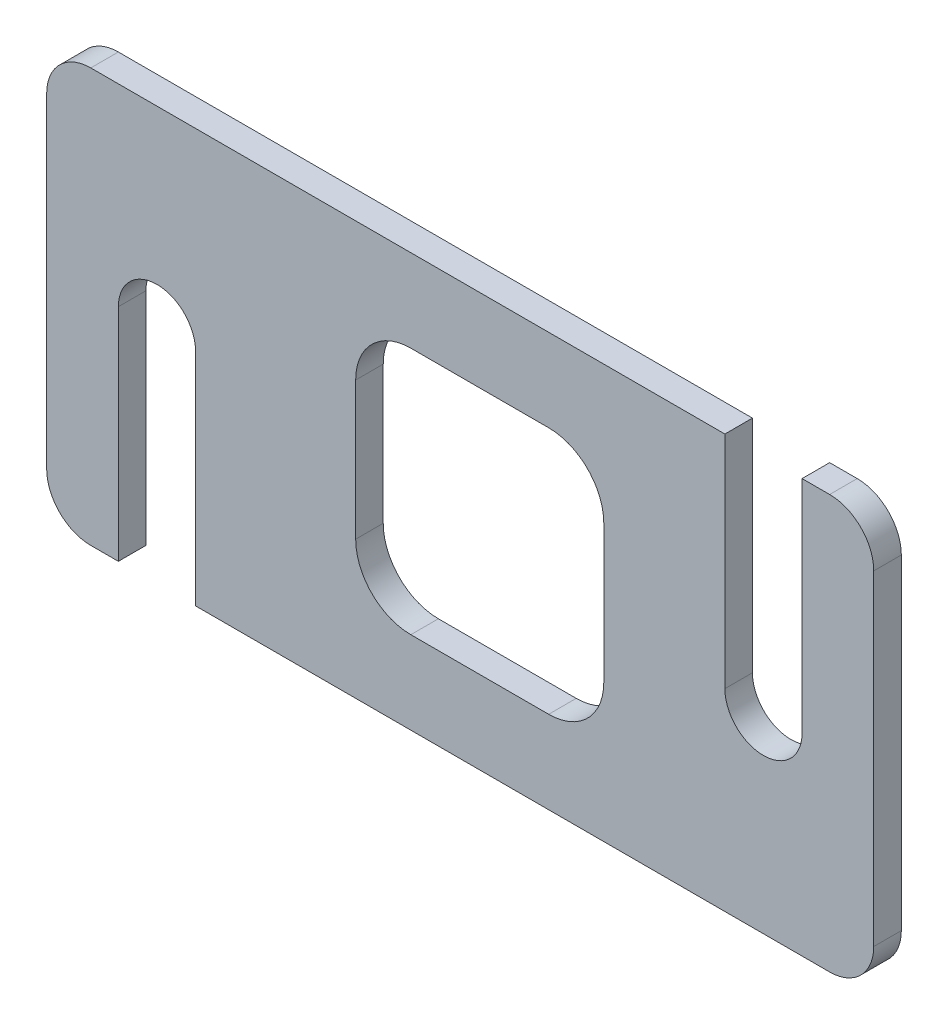
from build123d import *

# Parameters (mm, degrees)
SKETCH1_W                = 150
SKETCH1_H                = 75
BOSS_EXTRUDE2_DEPTH      = 5
CUT_EXTRUDE9_DEPTH       = 6
CUT_EXTRUDE9_DEPTH_BACK  = 1
CUT_EXTRUDE10_DEPTH      = 1
CUT_EXTRUDE10_DEPTH_BACK = 6
FILLET3_R                = 8
FILLET4_R                = 8
FILLET5_R                = 8
FILLET6_R                = 8


with BuildPart() as part:
    # Sketch1 → Boss-Extrude2 (new body)
    with BuildSketch(Plane.XY):
        with Locations((75, 37.5)):
            Rectangle(SKETCH1_W, SKETCH1_H)
    extrude(amount=BOSS_EXTRUDE2_DEPTH)

    # Sketch2 → Cut-Extrude9 (cut, two sides)
    with BuildSketch(Plane.XY) as cut_extrude9_sk:
        with BuildLine():
            Line((56.039864316, 50), (56.039864316, 25))
            ThreePointArc((56.039864316, 25), (58.968796504, 17.928932188), (66.039864316, 15))
            Line((66.039864316, 15), (91.039864316, 15))
            ThreePointArc((91.039864316, 15), (98.110932128, 17.928932188), (101.039864316, 25))
            Line((101.039864316, 25), (101.039864316, 50))
            ThreePointArc((101.039864316, 50), (98.110932128, 57.071067812), (91.039864316, 60))
            Line((91.039864316, 60), (66.039864316, 60))
            ThreePointArc((66.039864316, 60), (58.968796504, 57.071067812), (56.039864316, 50))
        make_face()
        with BuildLine():
            Line((13, 0), (13, 40))
            ThreePointArc((13, 40), (20, 47), (27, 40))
            Line((27, 40), (27, 0))
            ThreePointArc((27, 0), (20, -7), (13, 0))
        make_face()
    extrude(amount=CUT_EXTRUDE9_DEPTH, mode=Mode.SUBTRACT)
    extrude(cut_extrude9_sk.sketch, amount=-CUT_EXTRUDE9_DEPTH_BACK, mode=Mode.SUBTRACT)

    # Sketch3 → Cut-Extrude10 (cut, two sides)
    with BuildSketch(Plane.XY.offset(5)) as cut_extrude10_sk:
        with BuildLine():
            Line((123, 397.371573611), (123, 75))
            Line((123, 75), (123, 35))
            ThreePointArc((123, 35), (130, 28), (137, 35))
            Line((137, 35), (137, 75))
            Line((137, 75), (137, 397.371573611))
            Line((137, 397.371573611), (137, 1042.114720832))
            Line((137, 1042.114720832), (123, 1042.114720832))
            Line((123, 1042.114720832), (123, 397.371573611))
        make_face()
    extrude(amount=CUT_EXTRUDE10_DEPTH, mode=Mode.SUBTRACT)
    extrude(cut_extrude10_sk.sketch, amount=-CUT_EXTRUDE10_DEPTH_BACK, mode=Mode.SUBTRACT)

    # Fillet3
    fillet3_edges = [part.edges().sort_by_distance(p)[0] for p in [
        (150, 75, 2.5),
    ]]
    fillet(fillet3_edges, radius=FILLET3_R)

    # Fillet4
    fillet4_edges = [part.edges().sort_by_distance(p)[0] for p in [
        (0, 0, 2.5),
    ]]
    fillet(fillet4_edges, radius=FILLET4_R)

    # Fillet5
    fillet5_edges = [part.edges().sort_by_distance(p)[0] for p in [
        (150, 0, 2.5),
    ]]
    fillet(fillet5_edges, radius=FILLET5_R)

    # Fillet6
    fillet6_edges = [part.edges().sort_by_distance(p)[0] for p in [
        (0, 75, 2.5),
    ]]
    fillet(fillet6_edges, radius=FILLET6_R)


solid = part.part
